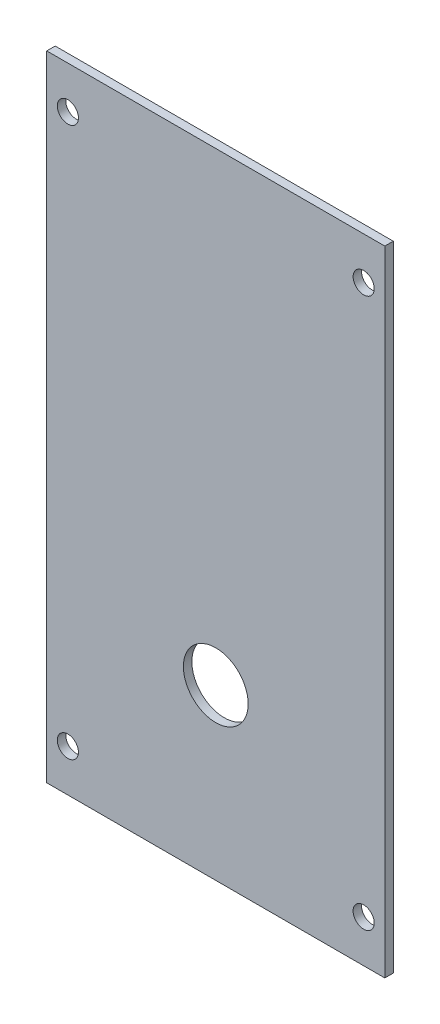
from build123d import *

# Parameters (mm, degrees)
SKETCH1_W           = 40
SKETCH1_H           = 75
SKETCH1_R           = 1.25
BOSS_EXTRUDE1_DEPTH = 1
SKETCH2_R           = 3.832032551
CUT_EXTRUDE1_DEPTH  = 10


with BuildPart() as part:
    # Sketch1 → Boss-Extrude1 (new body)
    with BuildSketch(Plane.XY):
        with Locations((1.951219512, 11.93902439)):
            Rectangle(SKETCH1_W, SKETCH1_H)
        with Locations((-15.548780488, 44.43902439)):
            Circle(SKETCH1_R, mode=Mode.SUBTRACT)
        with Locations((19.451219512, 44.43902439)):
            Circle(SKETCH1_R, mode=Mode.SUBTRACT)
        with Locations((19.451219512, -20.56097561)):
            Circle(SKETCH1_R, mode=Mode.SUBTRACT)
        with Locations((-15.548780488, -20.56097561)):
            Circle(SKETCH1_R, mode=Mode.SUBTRACT)
    extrude(amount=BOSS_EXTRUDE1_DEPTH)

    # Sketch2 → Cut-Extrude1 (cut)
    with BuildSketch(Plane.XY.offset(1)):
        with Locations((1.951219512, -5.56097561)):
            Circle(SKETCH2_R)
    extrude(amount=-CUT_EXTRUDE1_DEPTH, mode=Mode.SUBTRACT)


solid = part.part
